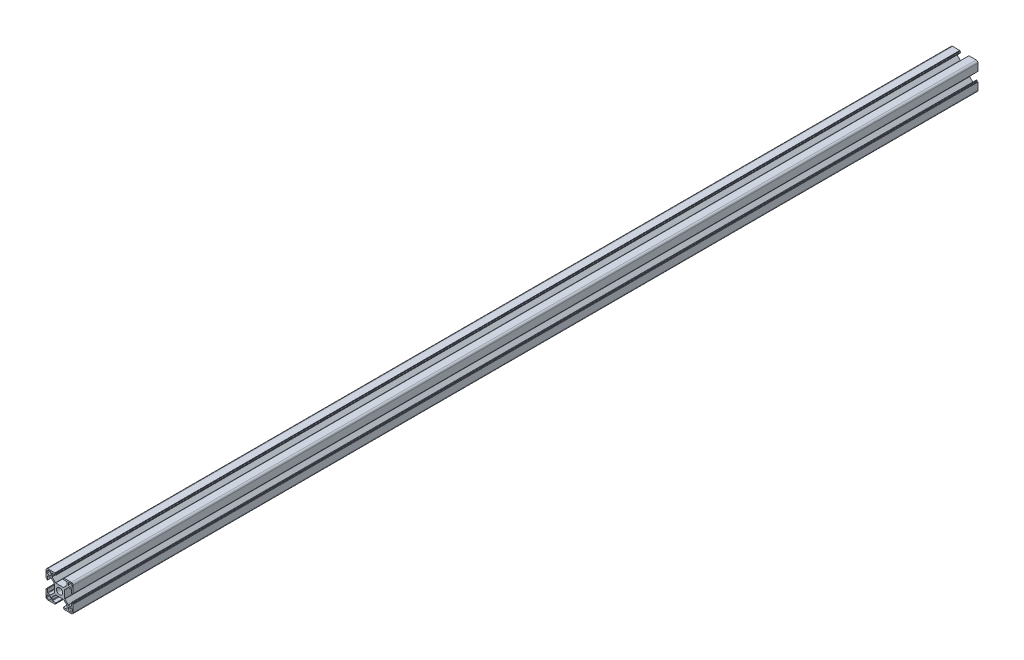
from build123d import *

# Parameters (mm, degrees)
SKETCH_1_W                       = 4
SKETCH_1_H                       = 4
EXTRUDE_1_DEPTH                  = 1000
FILLET_1_R                       = 1
FILLET_2_R                       = 2
FILLET_3_R                       = 0.5
PATTERN_CIRCULAR_1_COUNT         = 4
FILLET_1_OF_PATTERN_CIRCULAR_1_R = 1
FILLET_2_OF_PATTERN_CIRCULAR_1_R = 2
FILLET_3_OF_PATTERN_CIRCULAR_1_R = 0.5
SKETCH_2_R                       = 3.4
CUT_EXTRUDE_1_DEPTH              = 1001
SKETCH_3_R                       = 4
CUT_EXTRUDE_2_DEPTH              = 10
SKETCH_4_R                       = 3.1
SKETCH_4_R_2                     = 4.1
CUT_EXTRUDE_3_DEPTH              = 7.5


with BuildPart() as part:
    # 草图1 → 凸台-拉伸1 (new body)
    with BuildSketch(Plane.XY):
        Polygon((5.7, 0), (5.7, 4.427207794), (9.672792206, 8.4), (13.2, 8.4), (13.2, 4.1), (14.1, 4.1), (14.1, 5.1), (15, 5.1), (15, 15), (5.1, 15), (5.1, 14.1), (4.1, 14.1), (4.1, 13.2), (8.4, 13.2), (8.4, 9.672792206), (4.427207794, 5.7), (0, 5.7), (0, 0), align=None)
        with Locations((11.7, 11.7)):
            Rectangle(SKETCH_1_W, SKETCH_1_H, mode=Mode.SUBTRACT)
    extrude_1 = extrude(amount=EXTRUDE_1_DEPTH)

    # 圆角1
    fillet_1_edges = [part.edges().sort_by_distance(p)[0] for p in [
        (13.7, 9.7, 500),
        (13.7, 13.7, 500),
        (9.7, 13.7, 500),
        (9.7, 9.7, 500),
    ]]
    fillet(fillet_1_edges, radius=FILLET_1_R)

    # 圆角2
    fillet_2_edges = [part.edges().sort_by_distance(p)[0] for p in [
        (15, 15, 500),
    ]]
    fillet(fillet_2_edges, radius=FILLET_2_R)

    # 圆角3
    fillet_3_edges = [part.edges().sort_by_distance(p)[0] for p in [
        (4.427207794, 5.7, 500),
        (8.4, 9.672792206, 500),
        (8.4, 13.2, 500),
        (13.2, 8.4, 500),
        (9.672792206, 8.4, 500),
        (5.7, 4.427207794, 500),
    ]]
    fillet(fillet_3_edges, radius=FILLET_3_R)

    # 阵列(圆周)1: 凸台-拉伸1 ×4 about axis
    pattern_circular_1_axis = Axis((0, 0, 0), (0, 0, 1))
    for i in range(1, PATTERN_CIRCULAR_1_COUNT):
        add(extrude_1.rotate(pattern_circular_1_axis, i * 360 / PATTERN_CIRCULAR_1_COUNT))

    # 圆角1 of 阵列(圆周)1
    fillet_1_of_pattern_circular_1_edges = [part.edges().sort_by_distance(p)[0] for p in [
        (-9.7, 13.7, 500),
        (-13.7, 13.7, 500),
        (-13.7, 9.7, 500),
        (-9.7, 9.7, 500),
        (-13.7, -9.7, 500),
        (-13.7, -13.7, 500),
        (-9.7, -13.7, 500),
        (-9.7, -9.7, 500),
        (9.7, -13.7, 500),
        (13.7, -13.7, 500),
        (13.7, -9.7, 500),
        (9.7, -9.7, 500),
    ]]
    fillet(fillet_1_of_pattern_circular_1_edges, radius=FILLET_1_OF_PATTERN_CIRCULAR_1_R)

    # 圆角2 of 阵列(圆周)1
    fillet_2_of_pattern_circular_1_edges = [part.edges().sort_by_distance(p)[0] for p in [
        (-15, 15, 500),
        (-15, -15, 500),
        (15, -15, 500),
    ]]
    fillet(fillet_2_of_pattern_circular_1_edges, radius=FILLET_2_OF_PATTERN_CIRCULAR_1_R)

    # 圆角3 of 阵列(圆周)1
    fillet_3_of_pattern_circular_1_edges = [part.edges().sort_by_distance(p)[0] for p in [
        (-5.7, 4.427207794, 500),
        (-9.672792206, 8.4, 500),
        (-13.2, 8.4, 500),
        (-8.4, 13.2, 500),
        (-8.4, 9.672792206, 500),
        (-4.427207794, 5.7, 500),
        (-4.427207794, -5.7, 500),
        (-8.4, -9.672792206, 500),
        (-8.4, -13.2, 500),
        (-13.2, -8.4, 500),
        (-9.672792206, -8.4, 500),
        (-5.7, -4.427207794, 500),
        (5.7, -4.427207794, 500),
        (9.672792206, -8.4, 500),
        (13.2, -8.4, 500),
        (8.4, -13.2, 500),
        (8.4, -9.672792206, 500),
        (4.427207794, -5.7, 500),
    ]]
    fillet(fillet_3_of_pattern_circular_1_edges, radius=FILLET_3_OF_PATTERN_CIRCULAR_1_R)

    # 草图2 → 切除-拉伸1 (cut, through all)
    with BuildSketch(Plane.XY.offset(1000)):
        Circle(SKETCH_2_R)
    extrude(amount=-CUT_EXTRUDE_1_DEPTH, mode=Mode.SUBTRACT)

    # 草图3 → 切除-拉伸2 (cut, symmetric)
    with BuildSketch(Plane(origin=(0, 0, 0), x_dir=(1, 0, 0), z_dir=(0, 1, 0))):
        with Locations((0, -20)):
            Circle(SKETCH_3_R)
        with Locations((0, -980)):
            Circle(SKETCH_3_R)
        with BuildLine():
            Line((-4, -70), (-4, -80))
            ThreePointArc((-4, -80), (0, -84), (4, -80))
            Line((4, -80), (4, -70))
            ThreePointArc((4, -70), (0, -66), (-4, -70))
        make_face()
        with BuildLine():
            Line((4, -920), (4, -930))
            ThreePointArc((4, -930), (0, -934), (-4, -930))
            Line((-4, -930), (-4, -920))
            ThreePointArc((-4, -920), (0, -916), (4, -920))
        make_face()
    extrude(amount=CUT_EXTRUDE_2_DEPTH, both=True, mode=Mode.SUBTRACT)

    # 草图4 → 切除-拉伸3 (cut, symmetric)
    with BuildSketch(Plane(origin=(0, 0, 0), x_dir=(0, 0, -1), z_dir=(1, 0, 0))):
        with Locations((-945, 0)):
            Circle(SKETCH_4_R)
        with Locations((-915, 0)):
            Circle(SKETCH_4_R)
        with Locations((-85, 0)):
            Circle(SKETCH_4_R)
        with Locations((-55, 0)):
            Circle(SKETCH_4_R)
        with Locations((-500, 0)):
            Circle(SKETCH_4_R_2)
    extrude(amount=CUT_EXTRUDE_3_DEPTH, both=True, mode=Mode.SUBTRACT)


solid = part.part
